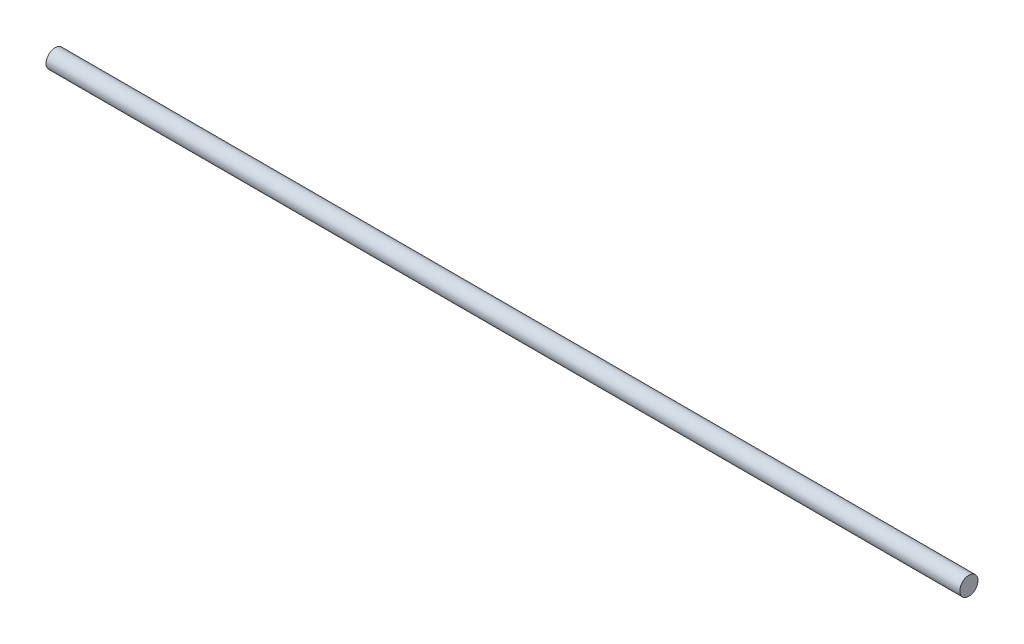
from build123d import *

# Parameters (mm, degrees)
SKETCH_1_W = 150
SKETCH_1_H = 1.5


with BuildPart() as part:
    # 草图1 → 旋转1 (revolve)
    with BuildSketch(Plane.XY):
        with Locations((49.26879054, -5.536605657)):
            Rectangle(SKETCH_1_W, SKETCH_1_H)
    revolve(axis=Axis((-25.73120946, -4.786605657, 0), (1, 0, 0)))


solid = part.part
